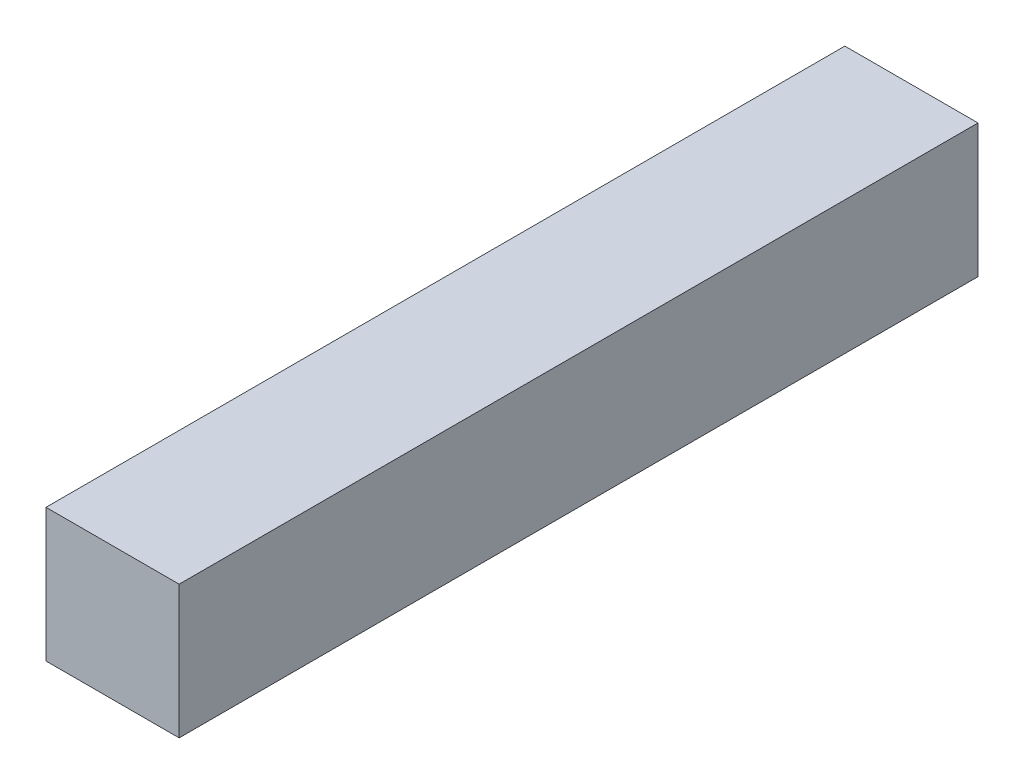
from build123d import *

# Parameters (mm, degrees)
SKETCH1_W           = 50
SKETCH1_H           = 50
BOSS_EXTRUDE1_DEPTH = 300


with BuildPart() as part:
    # Sketch1 → Boss-Extrude1 (new body)
    with BuildSketch(Plane.XY):
        Rectangle(SKETCH1_W, SKETCH1_H)
    extrude(amount=BOSS_EXTRUDE1_DEPTH)


solid = part.part
